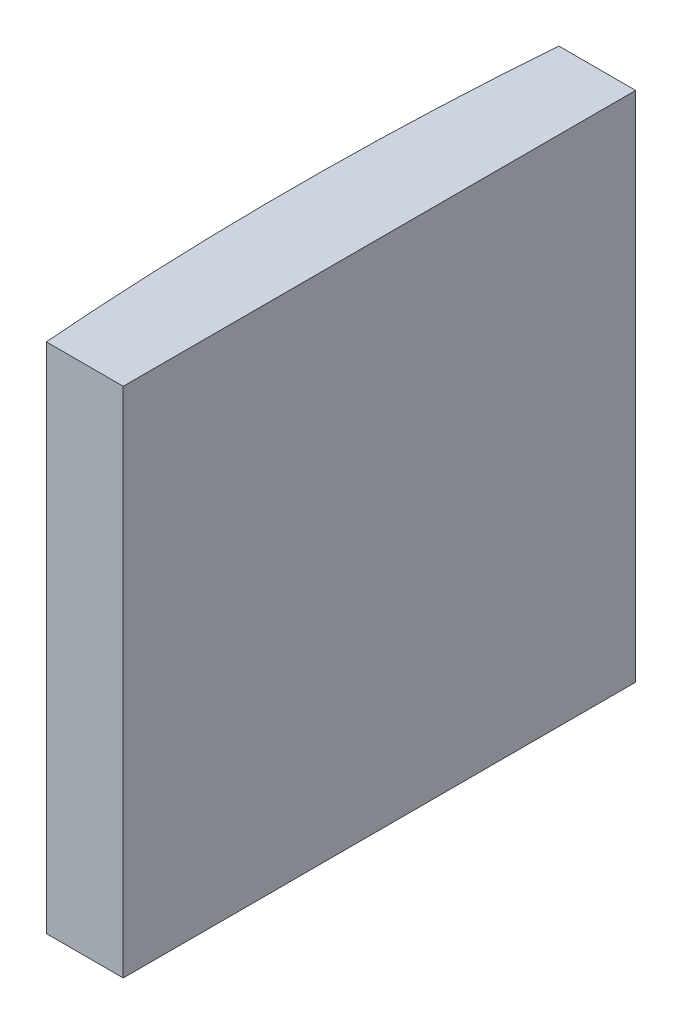
from build123d import *

# Parameters (mm, degrees)
EXTRUDE_1_DEPTH = 20


with BuildPart() as part:
    # 草图1 → 凸台-拉伸1 (new body)
    with BuildSketch(Plane(origin=(0, 0, 0), x_dir=(1, 0, 0), z_dir=(0, 1, 0))):
        with BuildLine():
            Line((-124.507367811, 10), (-121.504795665, 10))
            Line((-121.504795665, 10), (-121.504795665, -10))
            Line((-121.504795665, -10), (-124.507367811, -10))
            ThreePointArc((-124.507367811, -10), (-124.894795665, 0), (-124.507367811, 10))
        make_face()
    extrude(amount=EXTRUDE_1_DEPTH)


solid = part.part
